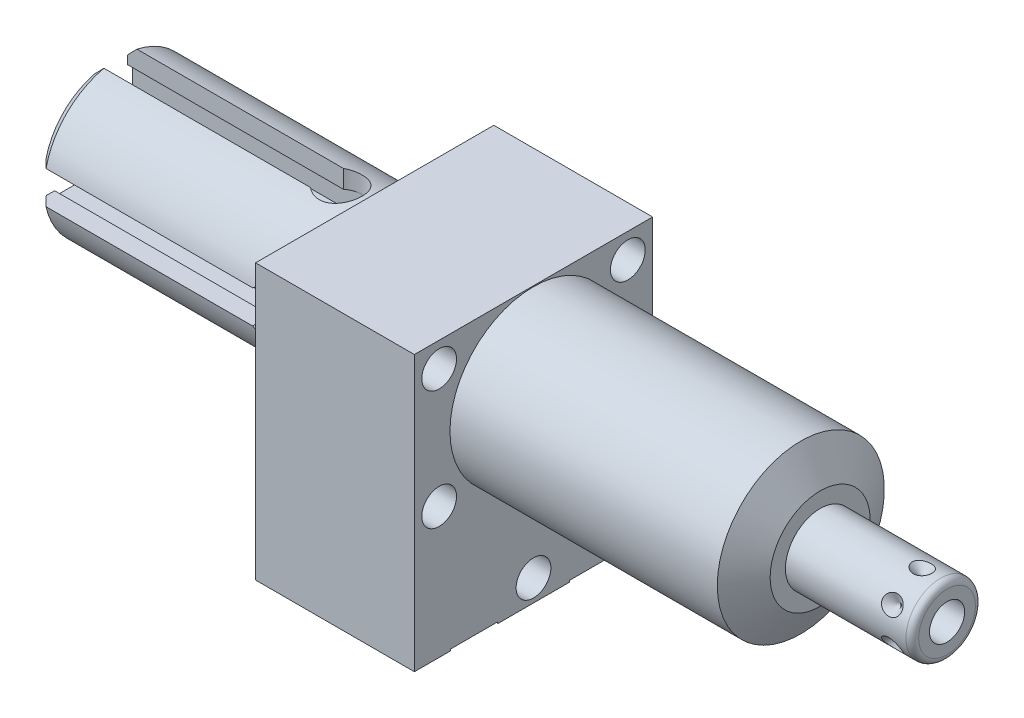
from build123d import *

# Parameters (mm, degrees)
SKETCH1_W           = 38.1
SKETCH1_H           = 43.942
EXTRUDE1_DEPTH      = 45.847
EXTRUDE1_DEPTH_BACK = 25.4
CUT_EXTRUDE1_REACH  = 47.847
SKETCH2_W           = 38.1
SKETCH2_H           = 43.942
SKETCH2_R           = 13.3604
SKETCH14_R          = 7.9375
CUT_EXTRUDE2_DEPTH  = 2.667
CIRPATTERN1_COUNT   = 6
HOLE1_D             = 5.5626
HOLE1_DEPTH         = 25.4
SKETCH18_R          = 1.7653
SKETCH19_R          = 11.3665
SKETCH19_R_2        = 11.1125
CUT_EXTRUDE3_DEPTH  = 2.921
CHAMFER1_SIZE       = 1.524
CUT_EXTRUDE4_DEPTH  = 36.7538
SKETCH22_R          = 3.429
CUT_EXTRUDE5_DEPTH  = 14.3477
CIRPATTERN2_COUNT   = 4


with BuildPart() as part:
    # Sketch1 → Extrude1 (new body, two sides)
    with BuildSketch(Plane(origin=(0, 0, 0), x_dir=(0, 0, -1), z_dir=(1, 0, 0))) as extrude1_sk:
        with Locations((0, -8.4836)):
            Rectangle(SKETCH1_W, SKETCH1_H)
    extrude(amount=EXTRUDE1_DEPTH)
    extrude(extrude1_sk.sketch, amount=-EXTRUDE1_DEPTH_BACK)

    # Sketch2 → Cut-Extrude1 (cut, up to next)
    with BuildSketch(Plane(origin=(0, 0, 0), x_dir=(0, 0, -1), z_dir=(1, 0, 0)), mode=Mode.PRIVATE) as cut_extrude1_sk1:
        with Locations((0, -8.4836)):
            Rectangle(SKETCH2_W, SKETCH2_H)
        Circle(SKETCH2_R, mode=Mode.SUBTRACT)
    cut_extrude1_tool1 = extrude(cut_extrude1_sk1.sketch, amount=CUT_EXTRUDE1_REACH, mode=Mode.PRIVATE) & part.part
    add(cut_extrude1_tool1.solids().sort_by_distance((0, 13.429241, 0))[0], mode=Mode.SUBTRACT)

    # Sketch3 → Cut-Revolve1 (revolve, cut)
    with BuildSketch(Plane.XY, mode=Mode.PRIVATE) as cut_revolve1_sk:
        Polygon((42.752748967, 13.3604), (45.847, 8.001), (45.847, 13.3604), align=None)
    revolve(cut_revolve1_sk.sketch.rotate(Axis((42.598036416, 0, 0), (1, 0, 0)), 90), axis=Axis((42.598036416, 0, 0), (1, 0, 0)), mode=Mode.SUBTRACT)  # turned: the seam where the file's is

    # S2D0002 → Cut-Revolve2 (revolve, cut)
    with BuildSketch(Plane(origin=(-22.733, -19.8374, 9.525), x_dir=(0, 1, 0), z_dir=(0, 0, 1)), mode=Mode.PRIVATE) as cut_revolve2_sk:
        Polygon((-0.8128, 0), (3.7338, 0), (3.293786662, -2.0701), (2.6416, -2.722286662), (2.6416, -13.97), (-0.8128, -13.97), align=None)
    revolve(cut_revolve2_sk.sketch.rotate(Axis((-8.0645, -20.6502, 9.525), (-1, 0, 0)), 90), axis=Axis((-8.0645, -20.6502, 9.525), (-1, 0, 0)), mode=Mode.SUBTRACT)  # turned: the seam where the file's is

    # Sketch5 → Cut-Revolve3 (revolve, cut)
    with BuildSketch(Plane(origin=(-22.733, -19.8374, -9.525), x_dir=(0, 1, 0), z_dir=(0, 0, 1)), mode=Mode.PRIVATE) as cut_revolve3_sk:
        Polygon((-0.8128, 0), (3.7338, 0), (3.293786662, -2.0701), (2.6416, -2.722286662), (2.6416, -13.97), (-0.8128, -13.97), align=None)
    revolve(cut_revolve3_sk.sketch.rotate(Axis((-8.0645, -20.6502, -9.525), (-1, 0, 0)), 90), axis=Axis((-8.0645, -20.6502, -9.525), (-1, 0, 0)), mode=Mode.SUBTRACT)  # turned: the seam where the file's is

    # Sketch14 → Cut-Extrude2 (cut)
    with BuildSketch(Plane.ZY.offset(25.4)):
        with Locations((-9.525, -20.6502)):
            Circle(SKETCH14_R)
        with Locations((9.525, -20.6502)):
            Circle(SKETCH14_R)
    extrude(amount=-CUT_EXTRUDE2_DEPTH, mode=Mode.SUBTRACT)

    # Sketch6 → Cut-Revolve4 (revolve, cut)
    with BuildSketch(Plane(origin=(-8.7376, -30.2006, 9.525), x_dir=(-1, 0, 0), z_dir=(0, 0, 1)), mode=Mode.PRIVATE) as cut_revolve4_sk:
        Polygon((6.18363, 0), (5.641036865, -2.5527), (4.97713, -3.216606865), (4.97713, -17.272), (0, -17.272), (0, 0), (0, 0.254), (9.52373, 0.254), (9.52373, 0), align=None)
    revolve(cut_revolve4_sk.sketch.rotate(Axis((-8.7376, -12.065, 9.525), (0, -1, 0)), 270), axis=Axis((-8.7376, -12.065, 9.525), (0, -1, 0)), mode=Mode.SUBTRACT)  # turned: the seam where the file's is

    # Sketch7 → Cut-Revolve5 (revolve, cut)
    with BuildSketch(Plane(origin=(-8.7376, -30.2006, -9.525), x_dir=(-1, 0, 0), z_dir=(0, 0, 1)), mode=Mode.PRIVATE) as cut_revolve5_sk:
        Polygon((6.1849, 0), (5.642306865, -2.5527), (4.9784, -3.216606865), (4.9784, -17.272), (0, -17.272), (0, 0), (0, 0.254), (9.52373, 0.254), (9.52373, 0), align=None)
    revolve(cut_revolve5_sk.sketch.rotate(Axis((-8.7376, -12.065, -9.525), (0, -1, 0)), 270), axis=Axis((-8.7376, -12.065, -9.525), (0, -1, 0)), mode=Mode.SUBTRACT)  # turned: the seam where the file's is

    # Sketch8 → Revolve1 (revolve)
    with BuildSketch(Plane.XY, mode=Mode.PRIVATE) as revolve1_sk:
        with BuildLine():
            Line((45.847, 0), (45.847, 5.55625))
            Line((45.847, 5.55625), (65.1256, 5.55625))
            ThreePointArc((65.1256, 5.55625), (65.84402049, 5.25867049), (66.1416, 4.54025))
            Line((66.1416, 4.54025), (66.1416, 0))
            Line((66.1416, 0), (45.847, 0))
        make_face()
    revolve(revolve1_sk.sketch.rotate(Axis((44.83227, 0, 0), (1, 0, 0)), 90), axis=Axis((44.83227, 0, 0), (1, 0, 0)))  # turned: the seam where the file's is

    # S2D0001 → Cut-Revolve6 (revolve, cut)
    with BuildSketch(Plane(origin=(66.1416, -2.8067, 0), x_dir=(0, -1, 0), z_dir=(0, 0, 1)), mode=Mode.PRIVATE) as cut_revolve6_sk:
        Polygon((0, 0), (0, -10.16), (-2.8067, -11.846435499), (-2.8067, 0), align=None)
    revolve(cut_revolve6_sk.sketch.rotate(Axis((53.702842726, 0, 0), (1, 0, 0)), 270), axis=Axis((53.702842726, 0, 0), (1, 0, 0)), mode=Mode.SUBTRACT)  # turned: the seam where the file's is

    # Sketch12 → Cut-Revolve7 (revolve, cut)
    with BuildSketch(Plane(origin=(62.1792, -5.55625, 0), x_dir=(-1, 0, 0), z_dir=(0, 0, 1)), mode=Mode.PRIVATE) as cut_revolve7_sk:
        Polygon((0, 0), (1.5875, 0), (0, -1.5875), align=None)
    cut_revolve7 = revolve(cut_revolve7_sk.sketch.rotate(Axis((62.1792, -2.12229387, 0), (0, -1, 0)), 90), axis=Axis((62.1792, -2.12229387, 0), (0, -1, 0)), mode=Mode.SUBTRACT)  # turned: the seam where the file's is

    # CirPattern1: Cut-Revolve7 ×6 about axis
    cirpattern1_axis = Axis((45.848, 0, 0), (-1, 0, 0))
    for i in range(1, CIRPATTERN1_COUNT):
        add(cut_revolve7.rotate(cirpattern1_axis, i * 360 / CIRPATTERN1_COUNT), mode=Mode.SUBTRACT)

    # Hole1
    with Locations(Plane(origin=(0, 0, 0), x_dir=(0, 0, -1), z_dir=(1, 0, 0))):
        with Locations((-15.0876, 9.525), (-15.0876, -9.525), (15.0876, 9.525), (15.0876, -9.525), (0, -26.9748)):
            Hole(HOLE1_D / 2, depth=HOLE1_DEPTH)

    # Sketch19 → Cut-Extrude3 (cut)
    with BuildSketch(Plane.ZY.offset(25.4)):
        Circle(SKETCH19_R)
        Circle(SKETCH19_R_2, mode=Mode.SUBTRACT)
    extrude(amount=-CUT_EXTRUDE3_DEPTH, mode=Mode.SUBTRACT)

    # Sketch20 → Revolve3 (revolve)
    with BuildSketch(Plane.XY, mode=Mode.PRIVATE) as revolve3_sk:
        Polygon((-25.4, 11.1125), (-26.0604, 11.1125), (-26.0604, 12.192), (-67.5894, 12.192), (-67.5894, 0), (-25.4, 0), align=None)
    revolve(revolve3_sk.sketch.rotate(Axis((0, 0, 0), (-1, 0, 0)), 270), axis=Axis((0, 0, 0), (-1, 0, 0)))  # turned: the seam where the file's is

    # Chamfer1
    chamfer1_edges = [part.edges().sort_by_distance(p)[0] for p in [
        (-67.5894, 0, -12.192),
    ]]
    chamfer(chamfer1_edges, length=CHAMFER1_SIZE)

    # Sketch21 → Cut-Extrude4 (cut)
    with BuildSketch(Plane.ZY.offset(67.5894)):
        with BuildLine():
            Line((11.90238688, 2.6416), (9.0043, 2.6416))
            Line((9.0043, 2.6416), (9.0043, 3.429))
            Line((9.0043, 3.429), (5.7023, 3.429))
            Line((5.7023, 3.429), (5.7023, -3.429))
            Line((5.7023, -3.429), (9.0043, -3.429))
            Line((9.0043, -3.429), (9.0043, -2.6416))
            Line((9.0043, -2.6416), (11.90238688, -2.6416))
            ThreePointArc((11.90238688, -2.6416), (12.192, 0), (11.90238688, 2.6416))
        make_face()
    cut_extrude4 = extrude(amount=-CUT_EXTRUDE4_DEPTH, mode=Mode.SUBTRACT)

    # Sketch22 → Cut-Extrude5 (cut, through all)
    with BuildSketch(Plane.XY.offset(5.7023)):
        with Locations((-30.8356, 0)):
            Circle(SKETCH22_R)
    cut_extrude5 = extrude(amount=CUT_EXTRUDE5_DEPTH, mode=Mode.SUBTRACT)

    # CirPattern2: Cut-Extrude4, Cut-Extrude5 ×4 about axis
    cirpattern2_axis = Axis((0, 0, 0), (1, 0, 0))
    add([cut_extrude4.rotate(cirpattern2_axis, i * 360 / CIRPATTERN2_COUNT) for i in range(1, CIRPATTERN2_COUNT)], mode=Mode.SUBTRACT)
    add([cut_extrude5.rotate(cirpattern2_axis, i * 360 / CIRPATTERN2_COUNT) for i in range(1, CIRPATTERN2_COUNT)], mode=Mode.SUBTRACT)


with BuildPart() as body_2:
    # Sketch18 → Revolve2 (revolve)
    with BuildSketch(Plane(origin=(-8.7376, -30.2006, 9.525), x_dir=(-1, 0, 0), z_dir=(0, 0, 1)), mode=Mode.PRIVATE) as revolve2_sk:
        with Locations((15.7607, -3.3782)):
            Circle(SKETCH18_R)
    revolve(revolve2_sk.sketch.rotate(Axis((-8.099075598, -20.6502, 9.525), (-1, 0, 0)), 90), axis=Axis((-8.099075598, -20.6502, 9.525), (-1, 0, 0)))  # turned: the seam where the file's is


solid = Compound([part.part, body_2.part])
